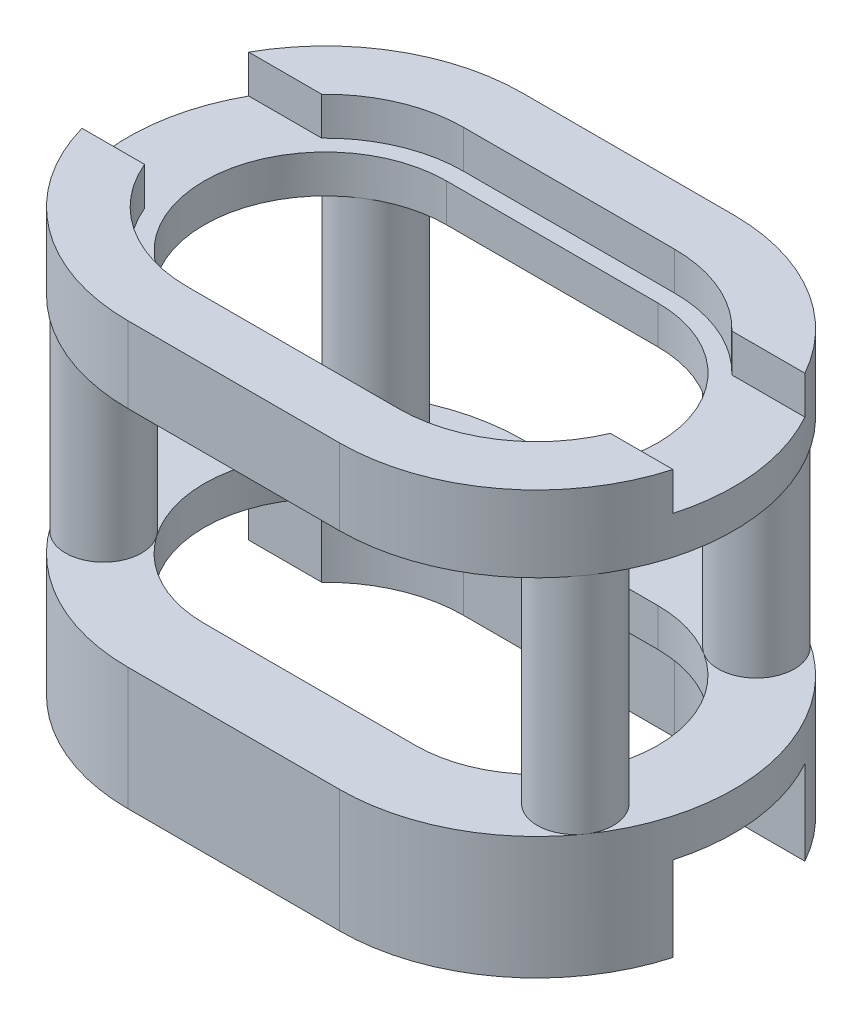
from build123d import *

# Parameters (mm, degrees)
BOSS_EXTRUDE1_DEPTH = 10
BOSS_EXTRUDE2_DEPTH = 7.1
SKETCH3_W           = 14.024598218
SKETCH3_H           = 5.3
CUT_EXTRUDE1_DEPTH  = 10
SKETCH4_W           = 15
SKETCH4_H           = 3.533
CUT_EXTRUDE2_DEPTH  = 0.9
SKETCH5_W           = 15
SKETCH5_H           = 3.533
CUT_EXTRUDE3_DEPTH  = 2
SKETCH7_R           = 0.9
BOSS_EXTRUDE3_DEPTH = 7.1
SKETCH8_W           = 2.379394034
SKETCH8_H           = 5.3
CUT_EXTRUDE4_DEPTH  = 15


with BuildPart() as part:
    # Sketch1 → Boss-Extrude1 (new body)
    with BuildSketch(Plane(origin=(0, 0, 0), x_dir=(1, 0, 0), z_dir=(0, 1, 0))):
        with BuildLine():
            Line((0, 4.6665), (5, 4.6665))
            ThreePointArc((5, 4.6665), (9.6665, 0), (5, -4.6665))
            Line((5, -4.6665), (0, -4.6665))
            ThreePointArc((0, -4.6665), (-4.6665, 0), (0, 4.6665))
        make_face()
        with BuildLine():
            Line((0, 3.2665), (5, 3.2665))
            ThreePointArc((5, 3.2665), (8.2665, 0), (5, -3.2665))
            Line((5, -3.2665), (0, -3.2665))
            ThreePointArc((0, -3.2665), (-3.2665, 0), (0, 3.2665))
        make_face(mode=Mode.SUBTRACT)
    extrude(amount=BOSS_EXTRUDE1_DEPTH)

    # Sketch2 → Boss-Extrude2 (add)
    with BuildSketch(Plane(origin=(0, 2, 0), x_dir=(1, 0, 0), z_dir=(0, 1, 0))):
        with BuildLine():
            Line((0, 3.2665), (5, 3.2665))
            ThreePointArc((5, 3.2665), (8.2665, 0), (5, -3.2665))
            Line((5, -3.2665), (0, -3.2665))
            ThreePointArc((0, -3.2665), (-3.2665, 0), (0, 3.2665))
        make_face()
        with BuildLine():
            Line((0, 2.8665), (5, 2.8665))
            ThreePointArc((5, 2.8665), (7.8665, 0), (5, -2.8665))
            Line((5, -2.8665), (0, -2.8665))
            ThreePointArc((0, -2.8665), (-2.8665, 0), (0, 2.8665))
        make_face(mode=Mode.SUBTRACT)
    extrude(amount=BOSS_EXTRUDE2_DEPTH)

    # Sketch3 → Cut-Extrude1 (cut)
    with BuildSketch(Plane.XY.offset(4.6665)):
        with Locations((2.500000001, 5.55)):
            Rectangle(SKETCH3_W, SKETCH3_H)
    extrude(amount=-CUT_EXTRUDE1_DEPTH, mode=Mode.SUBTRACT)

    # Sketch4 → Cut-Extrude2 (cut)
    with BuildSketch(Plane(origin=(0, 10, 0), x_dir=(1, 0, 0), z_dir=(0, 1, 0))):
        with Locations((2.5, 0.5)):
            Rectangle(SKETCH4_W, SKETCH4_H)
    extrude(amount=-CUT_EXTRUDE2_DEPTH, mode=Mode.SUBTRACT)

    # Sketch5 → Cut-Extrude3 (cut)
    with BuildSketch(Plane.XZ):
        with Locations((2.5, -0.5)):
            Rectangle(SKETCH5_W, SKETCH5_H)
    extrude(amount=-CUT_EXTRUDE3_DEPTH, mode=Mode.SUBTRACT)

    # Sketch7 → Boss-Extrude3 (add)
    with BuildSketch(Plane(origin=(0, 2, 0), x_dir=(1, 0, 0), z_dir=(0, 1, 0))):
        with Locations((-2.001737946, 3.19054344)):
            Circle(SKETCH7_R)
        with Locations((7.016622753, 3.181156224)):
            Circle(SKETCH7_R)
        with Locations((-3.081038786, -2.1665)):
            Circle(SKETCH7_R)
        with Locations((8.081038786, -2.1665)):
            Circle(SKETCH7_R)
    extrude(amount=BOSS_EXTRUDE3_DEPTH)

    # Sketch8 → Cut-Extrude4 (cut)
    with BuildSketch(Plane(origin=(10, 0, 0), x_dir=(0, 0, -1), z_dir=(1, 0, 0))):
        with Locations((0, 5.55)):
            Rectangle(SKETCH8_W, SKETCH8_H)
    extrude(amount=-CUT_EXTRUDE4_DEPTH, mode=Mode.SUBTRACT)


solid = part.part
